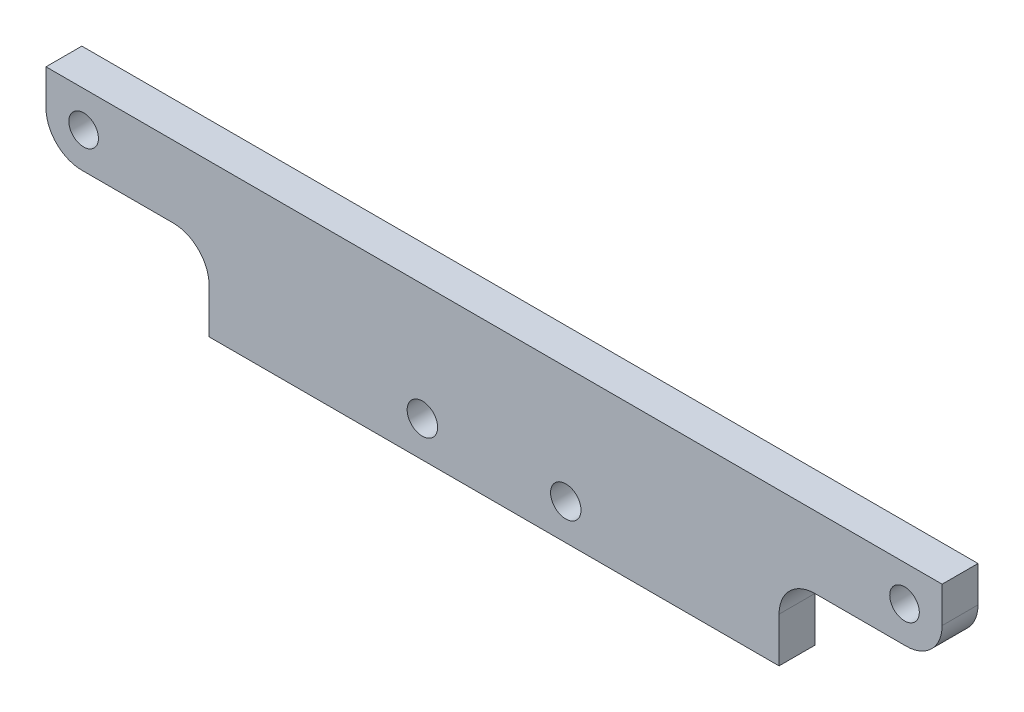
from build123d import *

# Parameters (mm, degrees)
SKETCH2_W             = 100
SKETCH2_H             = 17
BASE_DEPTH            = 2
M3_CLEARANCE_HOLE1_D  = 3.4
M4X0_7_TAPPED_HOLE1_D = 3.3
SKETCH9_W             = 18.2
SKETCH9_H             = 9
CUT_EXTRUDE1_DEPTH    = 10
FILLET3_R             = 4


with BuildPart() as part:
    # Sketch2 → Base (new body, symmetric)
    with BuildSketch(Plane.XY):
        with Locations((0, 8.5)):
            Rectangle(SKETCH2_W, SKETCH2_H)
    extrude(amount=BASE_DEPTH, both=True)

    # M3 Clearance Hole1 (through all)
    with Locations(Plane(origin=(0, 4, -2), x_dir=(1, 0, 0), z_dir=(0, 0, -1))):
        with Locations((-8, 0), (8, 0)):
            Hole(M3_CLEARANCE_HOLE1_D / 2)

    # M4x0.7 Tapped Hole1 (through all)
    with Locations(Plane(origin=(0, 0, -2), x_dir=(-1, 0, 0), z_dir=(0, 0, -1))):
        with Locations((-45.8, 13), (45.8, 13)):
            Hole(M4X0_7_TAPPED_HOLE1_D / 2)

    # Sketch9 → Cut-Extrude1 (cut)
    with BuildSketch(Plane(origin=(0, 0, -2), x_dir=(-1, 0, 0), z_dir=(0, 0, -1))):
        with Locations((40.9, 4.5)):
            Rectangle(SKETCH9_W, SKETCH9_H)
        with Locations((-40.9, 4.5)):
            Rectangle(SKETCH9_W, SKETCH9_H)
    extrude(amount=-CUT_EXTRUDE1_DEPTH, mode=Mode.SUBTRACT)

    # Fillet3
    fillet3_edges = [part.edges().sort_by_distance(p)[0] for p in [
        (-31.8, 9, 0),
        (-50, 9, 0),
        (50, 9, 0),
        (31.8, 9, 0),
    ]]
    fillet(fillet3_edges, radius=FILLET3_R)


solid = part.part
